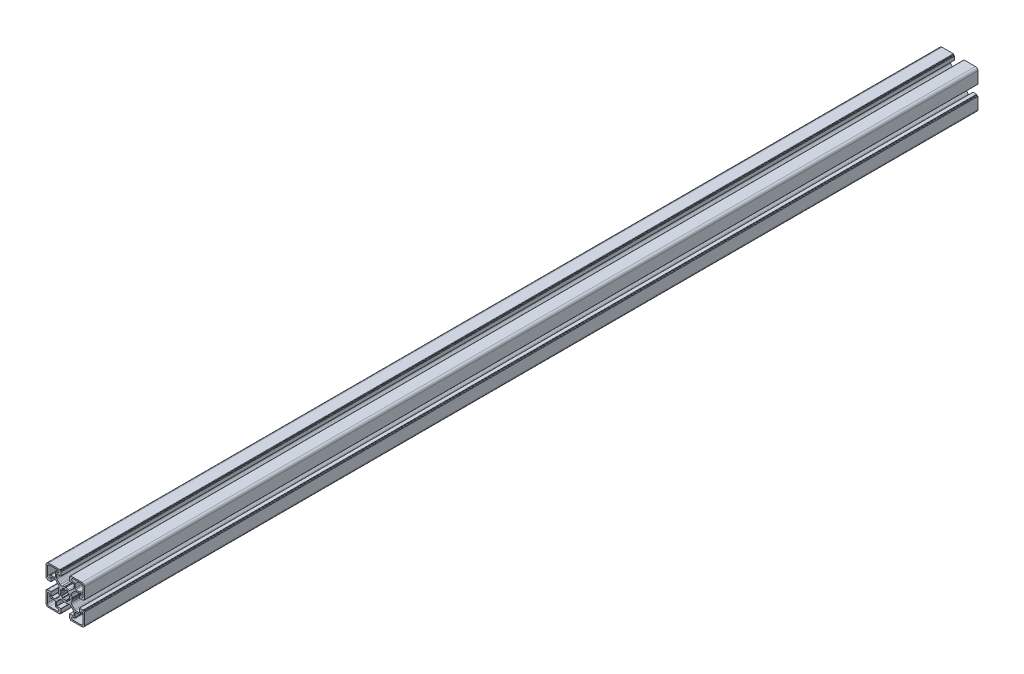
from build123d import *

# Parameters (mm, degrees)
BOSS_EXTRU_1_DEPTH = 1045


with BuildPart() as part:
    # Esquisse2 → Boss.-Extru.1 (new body)
    with BuildSketch(Plane.XY):
        with BuildLine():
            Line((-192.464705439, -351.135013575), (-192.030789329, -350.389251613))
            ThreePointArc((-192.030789329, -350.389251613), (-192.008099493, -350.33058749), (-192.004751867, -350.267777448))
            ThreePointArc((-192.004751867, -350.267777448), (-192.285035172, -348.883447185), (-192.804402464, -347.569983587))
            ThreePointArc((-192.804402464, -347.569983587), (-192.985908697, -346.38788866), (-192.44128198, -345.323147062))
            Line((-192.44128198, -345.323147062), (-188.874986025, -341.756855105))
            ThreePointArc((-188.874986025, -341.756855105), (-188.244141301, -341.335338521), (-187.500009401, -341.187321592))
            Line((-187.500009401, -341.187321592), (-183.687863463, -341.187321592))
            ThreePointArc((-183.687863463, -341.187321592), (-183.546441859, -341.245900338), (-183.487863113, -341.387321941))
            Line((-183.487863113, -341.387321941), (-183.487863113, -345.981828905))
            ThreePointArc((-183.487863113, -345.981828905), (-183.429284366, -346.12325051), (-183.287862762, -346.181829256))
            Line((-183.287862762, -346.181829256), (-179.285166009, -346.181829256))
            ThreePointArc((-179.285166009, -346.181829256), (-179.073034487, -346.093961503), (-178.985166733, -345.88182998))
            Line((-178.985166733, -345.88182998), (-178.985166733, -345.681839032))
            ThreePointArc((-178.985166733, -345.681839032), (-178.897298833, -345.469707156), (-178.685166958, -345.381839256))
            Line((-178.685166958, -345.381839256), (-178.0047864, -345.381839256))
            ThreePointArc((-178.0047864, -345.381839256), (-177.651233276, -345.235392756), (-177.504786776, -344.881839631))
            Line((-177.504786776, -344.881839631), (-177.504786776, -331.681827015))
            ThreePointArc((-177.504786776, -331.681827015), (-178.383465776, -329.560508257), (-180.504784534, -328.681829257))
            Line((-180.504784534, -328.681829257), (-193.629056903, -328.681829257))
            ThreePointArc((-193.629056903, -328.681829257), (-193.982610029, -328.828275756), (-194.129056529, -329.181828882))
            Line((-194.129056529, -329.181828882), (-194.129056529, -329.881829981))
            ThreePointArc((-194.129056529, -329.881829981), (-194.216924283, -330.093961503), (-194.429055805, -330.181829256))
            Line((-194.429055805, -330.181829256), (-194.70476714, -330.181829256))
            ThreePointArc((-194.70476714, -330.181829256), (-194.916898308, -330.269696863), (-195.004765915, -330.481828031))
            Line((-195.004765915, -330.481828031), (-195.004765915, -334.515030698))
            ThreePointArc((-195.004765915, -334.515030698), (-194.946187022, -334.656452656), (-194.804765065, -334.715031549))
            Line((-194.804765065, -334.715031549), (-190.099380697, -334.715031549))
            ThreePointArc((-190.099380697, -334.715031549), (-189.957959093, -334.773610295), (-189.899380347, -334.9150319))
            Line((-189.899380347, -334.9150319), (-189.899380347, -338.710260175))
            ThreePointArc((-189.899380347, -338.710260175), (-190.051621327, -339.47562727), (-190.48516696, -340.124474162))
            Line((-190.48516696, -340.124474162), (-194.059867926, -343.699175128))
            ThreePointArc((-194.059867926, -343.699175128), (-195.150164081, -344.214009408), (-196.338266679, -344.008553194))
            ThreePointArc((-196.338266679, -344.008553194), (-197.695629231, -343.467994797), (-199.128369878, -343.181829256))
            ThreePointArc((-199.128369878, -343.181829256), (-199.191201005, -343.184754557), (-199.250016338, -343.207049503))
            Line((-199.250016338, -343.207049503), (-199.892137456, -343.574906197))
            ThreePointArc((-199.892137456, -343.574906197), (-199.941802013, -343.622754392), (-200.004765916, -343.650889155))
            ThreePointArc((-200.004765916, -343.650889155), (-200.067729818, -343.622754392), (-200.117394375, -343.574906197))
            Line((-200.117394375, -343.574906197), (-200.759515492, -343.207049503))
            ThreePointArc((-200.759515492, -343.207049503), (-200.818330825, -343.184754557), (-200.881161953, -343.181829255))
            ThreePointArc((-200.881161953, -343.181829255), (-202.3139026, -343.467994797), (-203.671265152, -344.008553193))
            ThreePointArc((-203.671265152, -344.008553193), (-204.85936775, -344.214009407), (-205.949663904, -343.699175128))
            Line((-205.949663904, -343.699175128), (-209.52436487, -340.124474162))
            ThreePointArc((-209.52436487, -340.124474162), (-209.957910503, -339.475627269), (-210.110151485, -338.710260174))
            Line((-210.110151485, -338.710260174), (-210.110151485, -334.915031899))
            ThreePointArc((-210.110151485, -334.915031899), (-210.051572738, -334.773610295), (-209.910151134, -334.715031548))
            Line((-209.910151134, -334.715031548), (-205.204766766, -334.715031548))
            ThreePointArc((-205.204766766, -334.715031548), (-205.063344808, -334.656452656), (-205.004765915, -334.515030698))
            Line((-205.004765915, -334.515030698), (-205.004765915, -330.481828032))
            ThreePointArc((-205.004765915, -330.481828032), (-205.092633523, -330.269696863), (-205.304764692, -330.181829256))
            Line((-205.304764692, -330.181829256), (-205.580476025, -330.181829256))
            ThreePointArc((-205.580476025, -330.181829256), (-205.792607548, -330.093961502), (-205.880475302, -329.88182998))
            Line((-205.880475302, -329.88182998), (-205.880475302, -329.181828882))
            ThreePointArc((-205.880475302, -329.181828882), (-206.026921801, -328.828275756), (-206.380474927, -328.681829256))
            Line((-206.380474927, -328.681829256), (-219.504747296, -328.681829256))
            ThreePointArc((-219.504747296, -328.681829256), (-221.626066055, -329.560508256), (-222.504745055, -331.681827014))
            Line((-222.504745055, -331.681827014), (-222.504745055, -344.88183963))
            ThreePointArc((-222.504745055, -344.88183963), (-222.358298555, -345.235392756), (-222.00474543, -345.381839256))
            Line((-222.00474543, -345.381839256), (-221.324364871, -345.381839256))
            ThreePointArc((-221.324364871, -345.381839256), (-221.112232996, -345.469707157), (-221.024365096, -345.681839032))
            Line((-221.024365096, -345.681839032), (-221.024365096, -345.88182998))
            ThreePointArc((-221.024365096, -345.88182998), (-220.936497342, -346.093961503), (-220.724365819, -346.181829256))
            Line((-220.724365819, -346.181829256), (-216.721669067, -346.181829256))
            ThreePointArc((-216.721669067, -346.181829256), (-216.580247463, -346.12325051), (-216.521668717, -345.981828906))
            Line((-216.521668717, -345.981828906), (-216.521668717, -341.387321942))
            ThreePointArc((-216.521668717, -341.387321942), (-216.46308997, -341.245900338), (-216.321668366, -341.187321592))
            Line((-216.321668366, -341.187321592), (-212.509522428, -341.187321592))
            ThreePointArc((-212.509522428, -341.187321592), (-211.765390527, -341.335338522), (-211.134545803, -341.756855106))
            Line((-211.134545803, -341.756855106), (-207.568249848, -345.323147062))
            ThreePointArc((-207.568249848, -345.323147062), (-207.023623131, -346.38788866), (-207.205129364, -347.569983588))
            ThreePointArc((-207.205129364, -347.569983588), (-207.724496656, -348.883447186), (-208.004779961, -350.267777448))
            ThreePointArc((-208.004779961, -350.267777448), (-208.001432335, -350.33058749), (-207.978742499, -350.389251614))
            Line((-207.978742499, -350.389251614), (-207.54482639, -351.135013575))
            ThreePointArc((-207.54482639, -351.135013575), (-207.5390619, -351.158167493), (-207.536095855, -351.181843132))
            ThreePointArc((-207.536095855, -351.181843132), (-207.5390619, -351.20551877), (-207.54482639, -351.228672687))
            Line((-207.54482639, -351.228672687), (-207.978742499, -351.974434649))
            ThreePointArc((-207.978742499, -351.974434649), (-208.001432335, -352.033098773), (-208.004779962, -352.095908815))
            ThreePointArc((-208.004779962, -352.095908815), (-207.724496656, -353.480239077), (-207.205129364, -354.793702675))
            ThreePointArc((-207.205129364, -354.793702675), (-207.023623132, -355.975797603), (-207.568249848, -357.040539202))
            Line((-207.568249848, -357.040539202), (-211.134545804, -360.606831158))
            ThreePointArc((-211.134545804, -360.606831158), (-211.765390528, -361.028347742), (-212.509522429, -361.176364671))
            Line((-212.509522429, -361.176364671), (-216.321668366, -361.176364671))
            ThreePointArc((-216.321668366, -361.176364671), (-216.463089971, -361.117785925), (-216.521668717, -360.97636432))
            Line((-216.521668717, -360.97636432), (-216.521668717, -356.381857357))
            ThreePointArc((-216.521668717, -356.381857357), (-216.580247463, -356.240435753), (-216.721669067, -356.181857007))
            Line((-216.721669067, -356.181857007), (-220.72436582, -356.181857007))
            ThreePointArc((-220.72436582, -356.181857007), (-220.936497342, -356.26972476), (-221.024365096, -356.481856283))
            Line((-221.024365096, -356.481856283), (-221.024365096, -356.68184723))
            ThreePointArc((-221.024365096, -356.68184723), (-221.112232996, -356.893979106), (-221.324364871, -356.981847005))
            Line((-221.324364871, -356.981847005), (-222.004745429, -356.981847005))
            ThreePointArc((-222.004745429, -356.981847005), (-222.358298555, -357.128293506), (-222.504745055, -357.481846632))
            Line((-222.504745055, -357.481846632), (-222.504745055, -370.681859247))
            ThreePointArc((-222.504745055, -370.681859247), (-221.626066055, -372.803178006), (-219.504747296, -373.681857006))
            Line((-219.504747296, -373.681857006), (-206.380474927, -373.681857006))
            ThreePointArc((-206.380474927, -373.681857006), (-206.026921801, -373.535410506), (-205.880475301, -373.18185738))
            Line((-205.880475301, -373.18185738), (-205.880475301, -372.481856282))
            ThreePointArc((-205.880475301, -372.481856282), (-205.792607548, -372.269724759), (-205.580476025, -372.181857005))
            Line((-205.580476025, -372.181857005), (-205.304764691, -372.181857005))
            ThreePointArc((-205.304764691, -372.181857005), (-205.092633522, -372.093989398), (-205.004765915, -371.881858229))
            Line((-205.004765915, -371.881858229), (-205.004765915, -367.848655563))
            ThreePointArc((-205.004765915, -367.848655563), (-205.063344808, -367.707233605), (-205.204766766, -367.648654712))
            Line((-205.204766766, -367.648654712), (-209.910151134, -367.648654712))
            ThreePointArc((-209.910151134, -367.648654712), (-210.051572738, -367.590075966), (-210.110151485, -367.448654362))
            Line((-210.110151485, -367.448654362), (-210.110151485, -363.653426086))
            ThreePointArc((-210.110151485, -363.653426086), (-209.957910503, -362.888058992), (-209.524364871, -362.239212099))
            Line((-209.524364871, -362.239212099), (-205.949663905, -358.664511133))
            ThreePointArc((-205.949663905, -358.664511133), (-204.85936775, -358.149676855), (-203.671265152, -358.355133067))
            ThreePointArc((-203.671265152, -358.355133067), (-202.3139026, -358.895691464), (-200.881161954, -359.181857005))
            ThreePointArc((-200.881161954, -359.181857005), (-200.818330826, -359.178931703), (-200.759515493, -359.156636757))
            Line((-200.759515493, -359.156636757), (-200.117394376, -358.788780064))
            ThreePointArc((-200.117394376, -358.788780064), (-200.067729819, -358.740931869), (-200.004765916, -358.712797106))
            ThreePointArc((-200.004765916, -358.712797106), (-199.941802013, -358.740931869), (-199.892137456, -358.788780064))
            Line((-199.892137456, -358.788780064), (-199.250016339, -359.156636758))
            ThreePointArc((-199.250016339, -359.156636758), (-199.191201006, -359.178931704), (-199.128369878, -359.181857005))
            ThreePointArc((-199.128369878, -359.181857005), (-197.695629231, -358.895691464), (-196.338266679, -358.355133068))
            ThreePointArc((-196.338266679, -358.355133068), (-195.150164082, -358.149676855), (-194.059867927, -358.664511133))
            Line((-194.059867927, -358.664511133), (-190.48516696, -362.239212099))
            ThreePointArc((-190.48516696, -362.239212099), (-190.051621328, -362.888058992), (-189.899380348, -363.653426086))
            Line((-189.899380348, -363.653426086), (-189.899380348, -367.448654362))
            ThreePointArc((-189.899380348, -367.448654362), (-189.957959094, -367.590075965), (-190.099380697, -367.648654712))
            Line((-190.099380697, -367.648654712), (-194.804765066, -367.648654712))
            ThreePointArc((-194.804765066, -367.648654712), (-194.946187023, -367.707233605), (-195.004765916, -367.848655563))
            Line((-195.004765916, -367.848655563), (-195.004765916, -371.881858229))
            ThreePointArc((-195.004765916, -371.881858229), (-194.916898309, -372.093989397), (-194.70476714, -372.181857004))
            Line((-194.70476714, -372.181857004), (-194.429055806, -372.181857004))
            ThreePointArc((-194.429055806, -372.181857004), (-194.216924283, -372.269724758), (-194.12905653, -372.48185628))
            Line((-194.12905653, -372.48185628), (-194.12905653, -373.181857379))
            ThreePointArc((-194.12905653, -373.181857379), (-193.98261003, -373.535410505), (-193.629056903, -373.681857006))
            Line((-193.629056903, -373.681857006), (-180.504784534, -373.681857006))
            ThreePointArc((-180.504784534, -373.681857006), (-178.383465775, -372.803178005), (-177.504786775, -370.681859246))
            Line((-177.504786775, -370.681859246), (-177.504786775, -357.481846631))
            ThreePointArc((-177.504786775, -357.481846631), (-177.651233275, -357.128293504), (-178.004786402, -356.981847004))
            Line((-178.004786402, -356.981847004), (-178.685166959, -356.981847004))
            ThreePointArc((-178.685166959, -356.981847004), (-178.897298836, -356.893979105), (-178.985166735, -356.681847228))
            Line((-178.985166735, -356.681847228), (-178.985166735, -356.481856281))
            ThreePointArc((-178.985166735, -356.481856281), (-179.073034488, -356.269724759), (-179.28516601, -356.181857005))
            Line((-179.28516601, -356.181857005), (-183.287862762, -356.181857005))
            ThreePointArc((-183.287862762, -356.181857005), (-183.429284367, -356.240435752), (-183.487863113, -356.381857356))
            Line((-183.487863113, -356.381857356), (-183.487863113, -360.97636432))
            ThreePointArc((-183.487863113, -360.97636432), (-183.546441859, -361.117785924), (-183.687863463, -361.176364671))
            Line((-183.687863463, -361.176364671), (-187.500009401, -361.176364671))
            ThreePointArc((-187.500009401, -361.176364671), (-188.244141302, -361.028347742), (-188.874986026, -360.606831157))
            Line((-188.874986026, -360.606831157), (-192.441281982, -357.040539201))
            ThreePointArc((-192.441281982, -357.040539201), (-192.985908698, -355.975797602), (-192.804402465, -354.793702674))
            ThreePointArc((-192.804402465, -354.793702674), (-192.285035173, -353.480239077), (-192.004751867, -352.095908814))
            ThreePointArc((-192.004751867, -352.095908814), (-192.008099493, -352.033098772), (-192.030789329, -351.974434649))
            Line((-192.030789329, -351.974434649), (-192.464705438, -351.228672687))
            ThreePointArc((-192.464705438, -351.228672687), (-192.47046993, -351.20551877), (-192.473435973, -351.181843131))
            ThreePointArc((-192.473435973, -351.181843131), (-192.47046993, -351.158167492), (-192.464705439, -351.135013575))
        make_face()
        with BuildLine():
            Line((-195.08422015, -352.069665956), (-194.515035218, -352.16805429))
            ThreePointArc((-194.515035218, -352.16805429), (-194.165013852, -352.386136153), (-194.09791825, -352.793042574))
            ThreePointArc((-194.09791825, -352.793042574), (-194.353505931, -353.535154011), (-194.702268027, -354.238303673))
            ThreePointArc((-194.702268027, -354.238303673), (-195.035805071, -354.480613812), (-195.437988264, -354.390005633))
            Line((-195.437988264, -354.390005633), (-195.915053025, -354.058342475))
            ThreePointArc((-195.915053025, -354.058342475), (-196.474632965, -354.722769754), (-197.140765494, -355.280318651))
            Line((-197.140765494, -355.280318651), (-196.813454008, -355.744441346))
            ThreePointArc((-196.813454008, -355.744441346), (-196.720150548, -356.146118205), (-196.960380945, -356.481288596))
            ThreePointArc((-196.960380945, -356.481288596), (-197.665869942, -356.825320826), (-198.409694498, -357.075915978))
            ThreePointArc((-198.409694498, -357.075915978), (-198.816910196, -357.011432294), (-199.037244235, -356.662956066))
            Line((-199.037244235, -356.662956066), (-199.137377178, -356.106032077))
            ThreePointArc((-199.137377178, -356.106032077), (-200.004765915, -356.181843131), (-200.872154653, -356.106032077))
            Line((-200.872154653, -356.106032077), (-200.972287596, -356.662956066))
            ThreePointArc((-200.972287596, -356.662956066), (-201.192621634, -357.011432294), (-201.599837332, -357.075915978))
            ThreePointArc((-201.599837332, -357.075915978), (-202.343661888, -356.825320826), (-203.049150885, -356.481288596))
            ThreePointArc((-203.049150885, -356.481288596), (-203.289381283, -356.146118205), (-203.196077822, -355.744441346))
            Line((-203.196077822, -355.744441346), (-202.868766337, -355.280318651))
            ThreePointArc((-202.868766337, -355.280318651), (-203.534898866, -354.722769754), (-204.094478805, -354.058342475))
            Line((-204.094478805, -354.058342475), (-204.571543566, -354.390005633))
            ThreePointArc((-204.571543566, -354.390005633), (-204.97372676, -354.480613812), (-205.307263804, -354.238303673))
            ThreePointArc((-205.307263804, -354.238303673), (-205.6560259, -353.535154011), (-205.91161358, -352.793042574))
            ThreePointArc((-205.91161358, -352.793042574), (-205.844517979, -352.386136153), (-205.494496613, -352.16805429))
            Line((-205.494496613, -352.16805429), (-204.925311681, -352.069665956))
            ThreePointArc((-204.925311681, -352.069665956), (-205.004765916, -351.18184313), (-204.925311681, -350.294020305))
            Line((-204.925311681, -350.294020305), (-205.494496613, -350.195631971))
            ThreePointArc((-205.494496613, -350.195631971), (-205.844517979, -349.977550108), (-205.91161358, -349.570643686))
            ThreePointArc((-205.91161358, -349.570643686), (-205.6560259, -348.82853225), (-205.307263804, -348.125382588))
            ThreePointArc((-205.307263804, -348.125382588), (-204.97372676, -347.883072448), (-204.571543566, -347.973680627))
            Line((-204.571543566, -347.973680627), (-204.094478805, -348.305343785))
            ThreePointArc((-204.094478805, -348.305343785), (-203.534898866, -347.640916506), (-202.868766337, -347.08336761))
            Line((-202.868766337, -347.08336761), (-203.196077822, -346.619244915))
            ThreePointArc((-203.196077822, -346.619244915), (-203.289381283, -346.217568056), (-203.049150885, -345.882397665))
            ThreePointArc((-203.049150885, -345.882397665), (-202.343661888, -345.538365434), (-201.599837332, -345.287770282))
            ThreePointArc((-201.599837332, -345.287770282), (-201.192621634, -345.352253967), (-200.972287596, -345.700730195))
            Line((-200.972287596, -345.700730195), (-200.872154653, -346.257654184))
            ThreePointArc((-200.872154653, -346.257654184), (-200.004765915, -346.18184313), (-199.137377178, -346.257654184))
            Line((-199.137377178, -346.257654184), (-199.037244235, -345.700730195))
            ThreePointArc((-199.037244235, -345.700730195), (-198.816910196, -345.352253967), (-198.409694498, -345.287770282))
            ThreePointArc((-198.409694498, -345.287770282), (-197.665869942, -345.538365434), (-196.960380945, -345.882397665))
            ThreePointArc((-196.960380945, -345.882397665), (-196.720150548, -346.217568056), (-196.813454008, -346.619244915))
            Line((-196.813454008, -346.619244915), (-197.140765494, -347.08336761))
            ThreePointArc((-197.140765494, -347.08336761), (-196.474632965, -347.640916506), (-195.915053025, -348.305343785))
            Line((-195.915053025, -348.305343785), (-195.437988264, -347.973680627))
            ThreePointArc((-195.437988264, -347.973680627), (-195.035805071, -347.883072448), (-194.702268027, -348.125382588))
            ThreePointArc((-194.702268027, -348.125382588), (-194.353505931, -348.82853225), (-194.09791825, -349.570643686))
            ThreePointArc((-194.09791825, -349.570643686), (-194.165013852, -349.977550108), (-194.515035218, -350.195631971))
            Line((-194.515035218, -350.195631971), (-195.08422015, -350.294020305))
            ThreePointArc((-195.08422015, -350.294020305), (-195.004765915, -351.18184313), (-195.08422015, -352.069665956))
        make_face(mode=Mode.SUBTRACT)
        with BuildLine():
            Line((-191.004786777, -330.181829255), (-181.504784909, -330.181829255))
            ThreePointArc((-181.504784909, -330.181829255), (-179.737019277, -330.914061756), (-179.004786777, -332.681827388))
            Line((-179.004786777, -332.681827388), (-179.004786777, -342.181638256))
            ThreePointArc((-179.004786777, -342.181638256), (-180.504786777, -343.681638255), (-182.004786777, -342.181638255))
            Line((-182.004786777, -342.181638255), (-182.004786777, -340.631829508))
            ThreePointArc((-182.004786777, -340.631829508), (-182.297679777, -339.924723255), (-183.00478603, -339.631830255))
            Line((-183.00478603, -339.631830255), (-187.454788523, -339.631830255))
            ThreePointArc((-187.454788523, -339.631830255), (-188.161894777, -339.338937255), (-188.454787777, -338.631831002))
            Line((-188.454787777, -338.631831002), (-188.454787777, -334.181828508))
            ThreePointArc((-188.454787777, -334.181828508), (-188.747680777, -333.474722255), (-189.45478703, -333.181829255))
            Line((-189.45478703, -333.181829255), (-191.004786777, -333.181829255))
            ThreePointArc((-191.004786777, -333.181829255), (-192.504786777, -331.681829255), (-191.004786777, -330.181829255))
        make_face(mode=Mode.SUBTRACT)
        with BuildLine():
            Line((-221.004745053, -332.681827388), (-221.004745053, -342.181638256))
            ThreePointArc((-221.004745053, -342.181638256), (-219.504745053, -343.681638255), (-218.004745054, -342.181638255))
            Line((-218.004745054, -342.181638255), (-218.004745054, -340.631829508))
            ThreePointArc((-218.004745054, -340.631829508), (-217.711852054, -339.924723255), (-217.0047458, -339.631830255))
            Line((-217.0047458, -339.631830255), (-212.554743307, -339.631830255))
            ThreePointArc((-212.554743307, -339.631830255), (-211.847637054, -339.338937255), (-211.554744054, -338.631831002))
            Line((-211.554744054, -338.631831002), (-211.554744054, -334.181828508))
            ThreePointArc((-211.554744054, -334.181828508), (-211.261851054, -333.474722255), (-210.554744801, -333.181829255))
            Line((-210.554744801, -333.181829255), (-209.004745053, -333.181829255))
            ThreePointArc((-209.004745053, -333.181829255), (-207.504745054, -331.681829255), (-209.004745053, -330.181829255))
            Line((-209.004745053, -330.181829255), (-218.504746922, -330.181829255))
            ThreePointArc((-218.504746922, -330.181829255), (-220.272512554, -330.914061756), (-221.004745053, -332.681827388))
        make_face(mode=Mode.SUBTRACT)
        with BuildLine():
            Line((-191.004786777, -372.181857005), (-181.504784909, -372.181857005))
            ThreePointArc((-181.504784909, -372.181857005), (-179.737019277, -371.449624505), (-179.004786777, -369.681858873))
            Line((-179.004786777, -369.681858873), (-179.004786777, -360.182048004))
            ThreePointArc((-179.004786777, -360.182048004), (-180.504786777, -358.682048005), (-182.004786777, -360.182048005))
            Line((-182.004786777, -360.182048005), (-182.004786777, -361.731856752))
            ThreePointArc((-182.004786777, -361.731856752), (-182.297679777, -362.438963006), (-183.00478603, -362.731856006))
            Line((-183.00478603, -362.731856006), (-187.454788523, -362.731856006))
            ThreePointArc((-187.454788523, -362.731856006), (-188.161894777, -363.024749005), (-188.454787777, -363.731855258))
            Line((-188.454787777, -363.731855258), (-188.454787777, -368.181857752))
            ThreePointArc((-188.454787777, -368.181857752), (-188.747680777, -368.888964005), (-189.45478703, -369.181857005))
            Line((-189.45478703, -369.181857005), (-191.004786777, -369.181857005))
            ThreePointArc((-191.004786777, -369.181857005), (-192.504786777, -370.681857005), (-191.004786777, -372.181857005))
        make_face(mode=Mode.SUBTRACT)
        with BuildLine():
            Line((-209.004745053, -372.181857005), (-218.504746922, -372.181857005))
            ThreePointArc((-218.504746922, -372.181857005), (-220.272512554, -371.449624505), (-221.004745053, -369.681858873))
            Line((-221.004745053, -369.681858873), (-221.004745053, -360.182048004))
            ThreePointArc((-221.004745053, -360.182048004), (-219.504745053, -358.682048005), (-218.004745054, -360.182048005))
            Line((-218.004745054, -360.182048005), (-218.004745054, -361.731856752))
            ThreePointArc((-218.004745054, -361.731856752), (-217.711852054, -362.438963006), (-217.0047458, -362.731856006))
            Line((-217.0047458, -362.731856006), (-212.554743307, -362.731856006))
            ThreePointArc((-212.554743307, -362.731856006), (-211.847637054, -363.024749005), (-211.554744054, -363.731855258))
            Line((-211.554744054, -363.731855258), (-211.554744054, -368.181857752))
            ThreePointArc((-211.554744054, -368.181857752), (-211.261851054, -368.888964005), (-210.554744801, -369.181857005))
            Line((-210.554744801, -369.181857005), (-209.004745053, -369.181857005))
            ThreePointArc((-209.004745053, -369.181857005), (-207.504745054, -370.681857005), (-209.004745053, -372.181857005))
        make_face(mode=Mode.SUBTRACT)
    extrude(amount=BOSS_EXTRU_1_DEPTH)


solid = part.part
